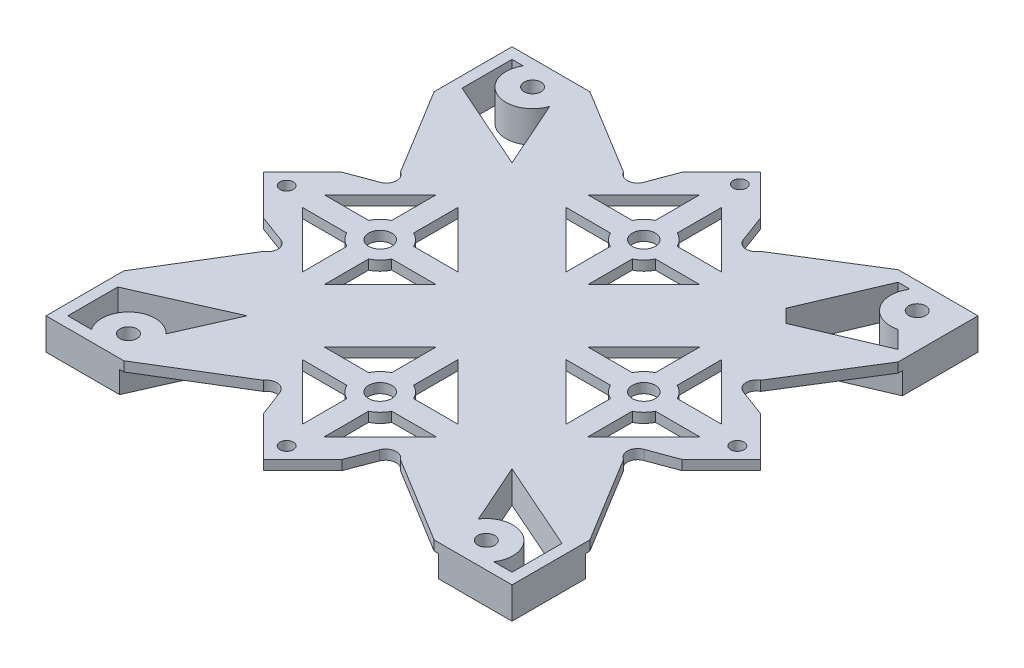
from build123d import *

# Parameters (mm, degrees)
SKETCH1_W            = 97.6
SKETCH1_H            = 97.6
BOSS_EXTRUDE1_DEPTH  = 2
SKETCH3_R            = 1.25
CUT_EXTRUDE1_DEPTH   = 10
FILLET1_R            = 0.2
SKETCH5_R            = 1.25
SKETCH5_R_2          = 1.248424064
SKETCH5_R_3          = 2.375
CUT_EXTRUDE2_DEPTH   = 10
SKETCH6_W            = 104.867444639
SKETCH6_H            = 104.070743389
SKETCH6_W_2          = 97.6
SKETCH6_H_2          = 97.6
BOSS_EXTRUDE2_DEPTH  = 2
SKETCH9_W            = 104.867444639
SKETCH9_H            = 104.070743389
CUT_EXTRUDE3_DEPTH   = 2
SKETCH11_R           = 1.25
BOSS_EXTRUDE3_DEPTH  = 4.5
CUT_EXTRUDE4_DEPTH   = 4.5
BOSS_EXTRUDE4_DEPTH  = 2
SKETCH15_R           = 1.25
SKETCH15_R_2         = 2.375
SKETCH15_R_3         = 1.248424064
CUT_EXTRUDE5_DEPTH   = 9.5
SKETCH16_R           = 1.25
BOSS_EXTRUDE10_DEPTH = 4.5
CUT_EXTRUDE6_DEPTH   = 1.85
SKETCH18_R           = 1.75
CUT_EXTRUDE7_DEPTH   = 14
BOSS_EXTRUDE11_DEPTH = 13
CUT_EXTRUDE10_DEPTH  = 11
CUT_EXTRUDE11_DEPTH  = 11
BOSS_EXTRUDE13_DEPTH = 2
SKETCH33_W           = 24.159337572
SKETCH33_H           = 13.360853571
SKETCH33_W_2         = 23.642161886
SKETCH33_H_2         = 13
CUT_EXTRUDE13_DEPTH  = 0.75
SKETCH34_W           = 20.408967788
SKETCH34_H           = 13
SKETCH34_W_2         = 21.119256586
CUT_EXTRUDE14_DEPTH  = 0.75
SKETCH35_W           = 21.001738999
SKETCH35_H           = 13
SKETCH35_W_2         = 20.166168151
CUT_EXTRUDE15_DEPTH  = 0.75
SKETCH36_W           = 19.371210598
SKETCH36_H           = 13
SKETCH36_W_2         = 18.340258541
CUT_EXTRUDE16_DEPTH  = 0.75
SKETCH38_R           = 1.25
SKETCH38_R_2         = 1.248424064
BOSS_EXTRUDE14_DEPTH = 2
SKETCH39_R           = 1.25
SKETCH39_R_2         = 1.248424064
BOSS_EXTRUDE15_DEPTH = 2
SKETCH40_R           = 1.375
CUT_EXTRUDE17_DEPTH  = 9.5
BOSS_EXTRUDE16_DEPTH = 13
SKETCH42_W           = 35.804322021
SKETCH42_H           = 4.5
CUT_EXTRUDE18_DEPTH  = 0.2
SKETCH43_W           = 35.804322021
SKETCH43_H           = 4.5
CUT_EXTRUDE19_DEPTH  = 0.2
SKETCH44_W           = 36.004322021
SKETCH44_H           = 4.5
SKETCH44_W_2         = 35.931129692
CUT_EXTRUDE20_DEPTH  = 0.2
SKETCH45_W           = 35.931129692
SKETCH45_H           = 4.5
SKETCH45_W_2         = 36.004322021
CUT_EXTRUDE21_DEPTH  = 0.2
SKETCH46_W           = 35.804322021
SKETCH46_H           = 4.5
CUT_EXTRUDE22_DEPTH  = 0.2
SKETCH47_W           = 35.804322021
SKETCH47_H           = 4.5
CUT_EXTRUDE23_DEPTH  = 0.2
SKETCH48_W           = 35.931129692
SKETCH48_H           = 4.5
SKETCH48_W_2         = 36.004322021
CUT_EXTRUDE24_DEPTH  = 0.2
SKETCH49_W           = 35.931129692
SKETCH49_H           = 4.5
SKETCH49_W_2         = 36.004322021
CUT_EXTRUDE25_DEPTH  = 0.2
SKETCH50_R           = 108.50704479
CUT_EXTRUDE26_DEPTH  = 6.5


with BuildPart() as part:
    # Sketch1 → Boss-Extrude1 (new body)
    with BuildSketch(Plane(origin=(0, 0, 0), x_dir=(1, 0, 0), z_dir=(0, 1, 0))):
        with Locations((48.8, 48.8)):
            Rectangle(SKETCH1_W, SKETCH1_H)
    extrude(amount=BOSS_EXTRUDE1_DEPTH)

    # Sketch3 → Cut-Extrude1 (cut)
    with BuildSketch(Plane.XZ):
        with BuildLine():
            Line((3, -84.3), (3, -94.6))
            Line((3, -94.6), (5.316079849, -94.6))
            ThreePointArc((5.316079849, -94.6), (7.792729855, -86.784550719), (15.285000001, -90.113353923))
            Line((15.285000001, -90.113353923), (21.472818771, -76.127181229))
            Line((21.472818771, -76.127181229), (3, -84.3))
        make_face()
        with BuildLine():
            Line((3, -13.3), (21.472818771, -21.472818771))
            Line((21.472818771, -21.472818771), (16.360495139, -9.917560959))
            ThreePointArc((16.360495139, -9.917560959), (8.975209709, -10.313312378), (7.873156109, -3))
            Line((7.873156109, -3), (3, -3))
            Line((3, -3), (3, -13.3))
        make_face()
        with BuildLine():
            Line((94.6, -13.3), (94.6, -3))
            Line((94.6, -3), (90.826843891, -3))
            ThreePointArc((90.826843891, -3), (89.267333256, -10.648445392), (81.630186258, -9.034513526))
            Line((81.630186258, -9.034513526), (76.127181229, -21.472818771))
            Line((76.127181229, -21.472818771), (94.6, -13.3))
        make_face()
        with BuildLine():
            Line((91.027327292, -86.172672708), (94.6, -82.6))
            Line((94.6, -82.6), (73.674141566, -73.674141566))
            Line((73.674141566, -73.674141566), (82.6, -94.6))
            Line((82.6, -94.6), (85.116873323, -94.6))
            ThreePointArc((85.116873323, -94.6), (85.157069093, -88.341897208), (91.027327292, -86.172672708))
        make_face()
        with Locations((89.66, -91.5)):
            Circle(SKETCH3_R)
        with Locations((10.05, -91.8)):
            Circle(SKETCH3_R)
        with Locations((12.45, -6.05)):
            Circle(SKETCH3_R)
        with Locations((86.25, -6.05)):
            Circle(SKETCH3_R)
    extrude(amount=-CUT_EXTRUDE1_DEPTH, mode=Mode.SUBTRACT)

    # Fillet1
    fillet1_edges = [part.edges().sort_by_distance(p)[0] for p in [
        (85.116873323, 1, -94.6),
    ]]
    fillet(fillet1_edges, radius=FILLET1_R)

    # Sketch5 → Cut-Extrude2 (cut)
    with BuildSketch(Plane.XZ):
        with BuildLine():
            Line((51.05, -80.617052601), (51.05, -89.767052601))
            Line((51.05, -89.767052601), (62.582493929, -78.234558673))
            Line((62.582493929, -78.234558673), (53.432493929, -78.234558673))
            ThreePointArc((53.432493929, -78.234558673), (52.441599923, -79.626158596), (51.05, -80.617052601))
        make_face()
        with BuildLine():
            Line((46.55, -89.767052601), (46.55, -80.617052601))
            ThreePointArc((46.55, -80.617052601), (45.158400077, -79.626158596), (44.167506071, -78.234558673))
            Line((44.167506071, -78.234558673), (35.017506071, -78.234558673))
            Line((35.017506071, -78.234558673), (46.55, -89.767052601))
        make_face()
        with BuildLine():
            Line((35.017506071, -73.734558673), (44.167506071, -73.734558673))
            ThreePointArc((44.167506071, -73.734558673), (45.158400077, -72.34295875), (46.55, -71.352064744))
            Line((46.55, -71.352064744), (46.55, -62.202064744))
            Line((46.55, -62.202064744), (35.017506071, -73.734558673))
        make_face()
        with BuildLine():
            ThreePointArc((51.05, -71.352064744), (52.441599923, -72.34295875), (53.432493929, -73.734558673))
            Line((53.432493929, -73.734558673), (62.582493929, -73.734558673))
            Line((62.582493929, -73.734558673), (51.05, -62.202064744))
            Line((51.05, -62.202064744), (51.05, -71.352064744))
        make_face()
        with BuildLine():
            Line((73.734558673, -35.017506071), (62.202064744, -46.55))
            Line((62.202064744, -46.55), (71.352064744, -46.55))
            ThreePointArc((71.352064744, -46.55), (72.34295875, -45.158400077), (73.734558673, -44.167506071))
            Line((73.734558673, -44.167506071), (73.734558673, -35.017506071))
        make_face()
        with BuildLine():
            ThreePointArc((73.734558673, -53.432493929), (72.34295875, -52.441599923), (71.352064744, -51.05))
            Line((71.352064744, -51.05), (62.202064744, -51.05))
            Line((62.202064744, -51.05), (73.734558673, -62.582493929))
            Line((73.734558673, -62.582493929), (73.734558673, -53.432493929))
        make_face()
        with BuildLine():
            Line((78.234558673, -35.017506071), (78.234558673, -44.167506071))
            ThreePointArc((78.234558673, -44.167506071), (79.626158596, -45.158400077), (80.617052601, -46.55))
            Line((80.617052601, -46.55), (89.767052601, -46.55))
            Line((89.767052601, -46.55), (78.234558673, -35.017506071))
        make_face()
        with BuildLine():
            ThreePointArc((80.617052601, -51.05), (79.626158596, -52.441599923), (78.234558673, -53.432493929))
            Line((78.234558673, -53.432493929), (78.234558673, -62.582493929))
            Line((78.234558673, -62.582493929), (89.767052601, -51.05))
            Line((89.767052601, -51.05), (80.617052601, -51.05))
        make_face()
        with BuildLine():
            Line((46.55, -16.982947399), (46.55, -7.832947399))
            Line((46.55, -7.832947399), (35.017506071, -19.365441327))
            Line((35.017506071, -19.365441327), (44.167506071, -19.365441327))
            ThreePointArc((44.167506071, -19.365441327), (45.158400077, -17.973841404), (46.55, -16.982947399))
        make_face()
        with BuildLine():
            Line((51.05, -7.832947399), (51.05, -16.982947399))
            ThreePointArc((51.05, -16.982947399), (52.441599923, -17.973841404), (53.432493929, -19.365441327))
            Line((53.432493929, -19.365441327), (62.582493929, -19.365441327))
            Line((62.582493929, -19.365441327), (51.05, -7.832947399))
        make_face()
        with BuildLine():
            ThreePointArc((46.55, -26.247935256), (45.158400077, -25.25704125), (44.167506071, -23.865441327))
            Line((44.167506071, -23.865441327), (35.017506071, -23.865441327))
            Line((35.017506071, -23.865441327), (46.55, -35.397935256))
            Line((46.55, -35.397935256), (46.55, -26.247935256))
        make_face()
        with BuildLine():
            Line((62.582493929, -23.865441327), (53.432493929, -23.865441327))
            ThreePointArc((53.432493929, -23.865441327), (52.441599923, -25.25704125), (51.05, -26.247935256))
            Line((51.05, -26.247935256), (51.05, -35.397935256))
            Line((51.05, -35.397935256), (62.582493929, -23.865441327))
        make_face()
        with BuildLine():
            Line((23.865441327, -62.582493929), (35.397935256, -51.05))
            Line((35.397935256, -51.05), (26.247935256, -51.05))
            ThreePointArc((26.247935256, -51.05), (25.25704125, -52.441599923), (23.865441327, -53.432493929))
            Line((23.865441327, -53.432493929), (23.865441327, -62.582493929))
        make_face()
        with BuildLine():
            Line((19.365441327, -62.582493929), (19.365441327, -53.432493929))
            ThreePointArc((19.365441327, -53.432493929), (17.973841404, -52.441599923), (16.982947399, -51.05))
            Line((16.982947399, -51.05), (7.832947399, -51.05))
            Line((7.832947399, -51.05), (19.365441327, -62.582493929))
        make_face()
        with BuildLine():
            ThreePointArc((23.865441327, -44.167506071), (25.25704125, -45.158400077), (26.247935256, -46.55))
            Line((26.247935256, -46.55), (35.397935256, -46.55))
            Line((35.397935256, -46.55), (23.865441327, -35.017506071))
            Line((23.865441327, -35.017506071), (23.865441327, -44.167506071))
        make_face()
        with BuildLine():
            Line((7.832947399, -46.55), (16.982947399, -46.55))
            ThreePointArc((16.982947399, -46.55), (17.973841404, -45.158400077), (19.365441327, -44.167506071))
            Line((19.365441327, -44.167506071), (19.365441327, -35.017506071))
            Line((19.365441327, -35.017506071), (7.832947399, -46.55))
        make_face()
        with Locations((48.8, -95.854595373)):
            Circle(SKETCH5_R)
        with Locations((95.84456992, -48.8)):
            Circle(SKETCH5_R_2)
        with Locations((1.75, -48.8)):
            Circle(SKETCH5_R)
        with Locations((48.8, -1.75)):
            Circle(SKETCH5_R)
        with Locations((48.8, -75.984558673)):
            Circle(SKETCH5_R_3)
        with Locations((75.984558673, -48.8)):
            Circle(SKETCH5_R_3)
        with Locations((48.8, -21.615441327)):
            Circle(SKETCH5_R_3)
        with Locations((21.615441327, -48.8)):
            Circle(SKETCH5_R_3)
    extrude(amount=-CUT_EXTRUDE2_DEPTH, mode=Mode.SUBTRACT)

    # Sketch6 → Boss-Extrude2 (add)
    with BuildSketch(Plane(origin=(0, 2, 0), x_dir=(1, 0, 0), z_dir=(0, 1, 0))):
        with Locations((49.842483603, 49.323375799)):
            Rectangle(SKETCH6_W, SKETCH6_H)
        with Locations((48.8, 48.8)):
            Rectangle(SKETCH6_W_2, SKETCH6_H_2, mode=Mode.SUBTRACT)
    extrude(amount=-BOSS_EXTRUDE2_DEPTH)

    # Sketch9 → Cut-Extrude3 (cut)
    with BuildSketch(Plane(origin=(0, 2, 0), x_dir=(1, 0, 0), z_dir=(0, 1, 0))):
        with Locations((49.842483603, 49.323375799)):
            Rectangle(SKETCH9_W, SKETCH9_H)
        Polygon((81.575043976, 97.6), (97.6, 97.6), (97.6, 81.575043976), (97.6, 51.29456992), (100.09456992, 48.8), (97.6, 46.30543008), (97.6, 15.581273054), (97.6, 0), (82.018726946, 0), (51.29456992, 0), (48.8, -2.49456992), (46.30543008, 0), (15.581273054, 0), (0, 0), (0, 15.581273054), (0, 46.30543008), (-2.49456992, 48.8), (0, 51.29456992), (0, 82.018726946), (0, 97.6), (15.581273054, 97.6), (46.30543008, 97.6), (48.8, 100.09456992), (51.29456992, 97.6), align=None, mode=Mode.SUBTRACT)
        with BuildLine():
            Line((40.668272016, 91.962841937), (46.30543008, 97.6))
            Line((46.30543008, 97.6), (15.581273054, 97.6))
            Line((15.581273054, 97.6), (34.657864376, 85.952434296))
            ThreePointArc((34.657864376, 85.952434296), (36.694771141, 84.840299118), (38.55, 86.234558673))
            Line((38.55, 86.234558673), (40.668272016, 91.962841937))
        make_face()
        with BuildLine():
            Line((62.942135624, 85.952434296), (81.575043976, 97.6))
            Line((81.575043976, 97.6), (51.29456992, 97.6))
            Line((51.29456992, 97.6), (56.931727984, 91.962841937))
            Line((56.931727984, 91.962841937), (59.05, 86.234558673))
            ThreePointArc((59.05, 86.234558673), (60.905228859, 84.840299118), (62.942135624, 85.952434296))
        make_face()
        with BuildLine():
            Line((97.6, 51.29456992), (97.6, 81.575043976))
            Line((97.6, 81.575043976), (85.952434296, 62.942135624))
            ThreePointArc((85.952434296, 62.942135624), (84.840299118, 60.905228859), (86.234558673, 59.05))
            Line((86.234558673, 59.05), (91.962841937, 56.931727984))
            Line((91.962841937, 56.931727984), (97.6, 51.29456992))
        make_face()
        with BuildLine():
            Line((97.6, 15.581273054), (97.6, 46.30543008))
            Line((97.6, 46.30543008), (91.962841937, 40.668272016))
            Line((91.962841937, 40.668272016), (86.234558673, 38.55))
            ThreePointArc((86.234558673, 38.55), (84.840299118, 36.694771141), (85.952434296, 34.657864376))
            Line((85.952434296, 34.657864376), (97.6, 15.581273054))
        make_face()
        with BuildLine():
            Line((51.29456992, 0), (82.018726946, 0))
            Line((82.018726946, 0), (62.942135624, 11.647565704))
            ThreePointArc((62.942135624, 11.647565704), (60.858639354, 12.601902927), (59.05, 11.194586358))
            Line((59.05, 11.194586358), (56.931727984, 5.637158063))
            Line((56.931727984, 5.637158063), (51.29456992, 0))
        make_face()
        with BuildLine():
            Line((15.581273054, 0), (46.30543008, 0))
            Line((46.30543008, 0), (40.668272016, 5.637158063))
            Line((40.668272016, 5.637158063), (38.55, 11.194586358))
            ThreePointArc((38.55, 11.194586358), (36.741360646, 12.601902927), (34.657864376, 11.647565704))
            Line((34.657864376, 11.647565704), (15.581273054, 0))
        make_face()
        with BuildLine():
            Line((5.637158063, 40.668272016), (0, 46.30543008))
            Line((0, 46.30543008), (0, 15.581273054))
            Line((0, 15.581273054), (11.647565704, 34.657864376))
            ThreePointArc((11.647565704, 34.657864376), (12.759700882, 36.694771141), (11.365441327, 38.55))
            Line((11.365441327, 38.55), (5.637158063, 40.668272016))
        make_face()
        with BuildLine():
            Line((11.647565704, 62.942135624), (0, 82.018726946))
            Line((0, 82.018726946), (0, 51.29456992))
            Line((0, 51.29456992), (5.637158063, 56.931727984))
            Line((5.637158063, 56.931727984), (11.365441327, 59.05))
            ThreePointArc((11.365441327, 59.05), (12.759700882, 60.905228859), (11.647565704, 62.942135624))
        make_face()
    extrude(amount=-CUT_EXTRUDE3_DEPTH, mode=Mode.SUBTRACT)

    # Sketch11 → Boss-Extrude3 (add)
    with BuildSketch(Plane.XZ):
        Polygon((97.6, -97.6), (81.575043976, -97.6), (69.655336569, -69.655336569), (97.6, -81.575043976), align=None)
        with Locations((89.66, -91.5)):
            Circle(SKETCH11_R, mode=Mode.SUBTRACT)
        with BuildLine():
            ThreePointArc((84.752862341, -94.6), (84.926573132, -94.499118926), (84.92504261, -94.298245614))
            ThreePointArc((84.92504261, -94.298245614), (85.26210654, -88.197193145), (91.027327292, -86.172672708))
            Line((91.027327292, -86.172672708), (94.6, -82.6))
            Line((94.6, -82.6), (73.674141566, -73.674141566))
            Line((73.674141566, -73.674141566), (82.6, -94.6))
            Line((82.6, -94.6), (84.752862341, -94.6))
        make_face(mode=Mode.SUBTRACT)
        Polygon((48.8, -49.789949494), (47.810050506, -48.8), (26.169211238, -70.440839268), (27.944663431, -69.655336569), (27.159160732, -71.430788762), align=None)
        Polygon((71.430788762, -27.159160732), (69.655336569, -27.944663431), (70.440839268, -26.169211238), (48.8, -47.810050506), (49.789949494, -48.8), align=None)
        Polygon((47.810050506, -48.8), (48.8, -47.810050506), (27.159160732, -26.169211238), (27.944663431, -27.944663431), (26.169211238, -27.159160732), align=None)
        Polygon((71.381631816, -70.391682322), (49.789949494, -48.8), (48.8, -49.789949494), (70.391682322, -71.381631816), (69.655336569, -69.655336569), align=None)
        Polygon((49.789949494, -48.8), (48.8, -47.810050506), (47.810050506, -48.8), (48.8, -49.789949494), align=None)
        Polygon((15.581273054, -97.6), (0, -97.6), (0, -82.018726946), (27.944663431, -69.655336569), align=None)
        with Locations((10.05, -91.8)):
            Circle(SKETCH11_R, mode=Mode.SUBTRACT)
        with BuildLine():
            Line((21.472818771, -76.127181229), (15.285000001, -90.113353923))
            ThreePointArc((15.285000001, -90.113353923), (7.792729855, -86.784550719), (5.316079849, -94.6))
            Line((5.316079849, -94.6), (3, -94.6))
            Line((3, -94.6), (3, -84.3))
            Line((3, -84.3), (21.472818771, -76.127181229))
        make_face(mode=Mode.SUBTRACT)
        Polygon((0, 0), (15.581273054, 0), (27.944663431, -27.944663431), (0, -15.581273054), align=None)
        with Locations((12.45, -6.05)):
            Circle(SKETCH11_R, mode=Mode.SUBTRACT)
        with BuildLine():
            Line((3, -3), (7.873156109, -3))
            ThreePointArc((7.873156109, -3), (8.975209709, -10.313312378), (16.360495139, -9.917560959))
            Line((16.360495139, -9.917560959), (21.472818771, -21.472818771))
            Line((21.472818771, -21.472818771), (3, -13.3))
            Line((3, -13.3), (3, -3))
        make_face(mode=Mode.SUBTRACT)
        Polygon((82.018726946, 0), (97.6, 0), (97.6, -15.581273054), (69.655336569, -27.944663431), align=None)
        with Locations((86.25, -6.05)):
            Circle(SKETCH11_R, mode=Mode.SUBTRACT)
        with BuildLine():
            Line((76.127181229, -21.472818771), (81.630186258, -9.034513526))
            ThreePointArc((81.630186258, -9.034513526), (89.267333256, -10.648445392), (90.826843891, -3))
            Line((90.826843891, -3), (94.6, -3))
            Line((94.6, -3), (94.6, -13.3))
            Line((94.6, -13.3), (76.127181229, -21.472818771))
        make_face(mode=Mode.SUBTRACT)
    extrude(amount=BOSS_EXTRUDE3_DEPTH)

    # Sketch12 → Cut-Extrude4 (cut)
    with BuildSketch(Plane.XZ.offset(4.5)):
        Polygon((26.876318019, -71.14794605), (71.148273589, -26.875990479), (70.724009521, -26.451726411), (26.45205395, -70.723681981), align=None)
        Polygon((26.45205395, -26.876318019), (70.724009521, -71.148273589), (71.148273589, -70.724009521), (26.876318019, -26.45205395), align=None)
    extrude(amount=-CUT_EXTRUDE4_DEPTH, mode=Mode.SUBTRACT)

    # Sketch13 → Boss-Extrude4 (add)
    with BuildSketch(Plane.XZ.offset(4.5)):
        with BuildLine():
            Line((0, -97.6), (0, -82.018726946))
            Line((0, -82.018726946), (11.647565704, -62.942135624))
            ThreePointArc((11.647565704, -62.942135624), (12.759700882, -60.905228859), (11.365441327, -59.05))
            Line((11.365441327, -59.05), (5.637158063, -56.931727984))
            Line((5.637158063, -56.931727984), (-2.49456992, -48.8))
            Line((-2.49456992, -48.8), (5.637158063, -40.668272016))
            Line((5.637158063, -40.668272016), (11.365441327, -38.55))
            ThreePointArc((11.365441327, -38.55), (12.759700882, -36.694771141), (11.647565704, -34.657864376))
            Line((11.647565704, -34.657864376), (0, -15.581273054))
            Line((0, -15.581273054), (0, 0))
            Line((0, 0), (15.581273054, 0))
            Line((15.581273054, 0), (34.657864376, -11.647565704))
            ThreePointArc((34.657864376, -11.647565704), (36.741360646, -12.601902927), (38.55, -11.194586358))
            Line((38.55, -11.194586358), (40.668272016, -5.637158063))
            Line((40.668272016, -5.637158063), (48.8, 2.49456992))
            Line((48.8, 2.49456992), (56.931727984, -5.637158063))
            Line((56.931727984, -5.637158063), (59.05, -11.194586358))
            ThreePointArc((59.05, -11.194586358), (60.858639354, -12.601902927), (62.942135624, -11.647565704))
            Line((62.942135624, -11.647565704), (82.018726946, 0))
            Line((82.018726946, 0), (97.6, 0))
            Line((97.6, 0), (97.6, -15.581273054))
            Line((97.6, -15.581273054), (85.952434296, -34.657864376))
            ThreePointArc((85.952434296, -34.657864376), (84.840299118, -36.694771141), (86.234558673, -38.55))
            Line((86.234558673, -38.55), (91.962841937, -40.668272016))
            Line((91.962841937, -40.668272016), (100.09456992, -48.8))
            Line((100.09456992, -48.8), (91.962841937, -56.931727984))
            Line((91.962841937, -56.931727984), (86.234558673, -59.05))
            ThreePointArc((86.234558673, -59.05), (84.840299118, -60.905228859), (85.952434296, -62.942135624))
            Line((85.952434296, -62.942135624), (97.6, -81.575043976))
            Line((97.6, -81.575043976), (97.6, -97.6))
            Line((97.6, -97.6), (81.575043976, -97.6))
            Line((81.575043976, -97.6), (62.942135624, -85.952434296))
            ThreePointArc((62.942135624, -85.952434296), (60.905228859, -84.840299118), (59.05, -86.234558673))
            Line((59.05, -86.234558673), (56.931727984, -91.962841937))
            Line((56.931727984, -91.962841937), (48.8, -100.09456992))
            Line((48.8, -100.09456992), (40.668272016, -91.962841937))
            Line((40.668272016, -91.962841937), (38.55, -86.234558673))
            ThreePointArc((38.55, -86.234558673), (36.694771141, -84.840299118), (34.657864376, -85.952434296))
            Line((34.657864376, -85.952434296), (15.581273054, -97.6))
            Line((15.581273054, -97.6), (0, -97.6))
        make_face()
    extrude(amount=BOSS_EXTRUDE4_DEPTH)

    # Sketch15 → Cut-Extrude5 (cut, through all)
    with BuildSketch(Plane.XZ.offset(6.5)):
        with BuildLine():
            ThreePointArc((53.432493929, -73.734558673), (52.441599923, -72.34295875), (51.05, -71.352064744))
            Line((51.05, -71.352064744), (51.05, -62.202064744))
            Line((51.05, -62.202064744), (62.582493929, -73.734558673))
            Line((62.582493929, -73.734558673), (53.432493929, -73.734558673))
        make_face()
        with BuildLine():
            ThreePointArc((51.05, -80.617052601), (52.441599923, -79.626158596), (53.432493929, -78.234558673))
            Line((53.432493929, -78.234558673), (62.582493929, -78.234558673))
            Line((62.582493929, -78.234558673), (51.05, -89.767052601))
            Line((51.05, -89.767052601), (51.05, -80.617052601))
        make_face()
        with BuildLine():
            ThreePointArc((44.167506071, -78.234558673), (45.158400077, -79.626158596), (46.55, -80.617052601))
            Line((46.55, -80.617052601), (46.55, -89.767052601))
            Line((46.55, -89.767052601), (35.017506071, -78.234558673))
            Line((35.017506071, -78.234558673), (44.167506071, -78.234558673))
        make_face()
        with BuildLine():
            ThreePointArc((46.55, -71.352064744), (45.158400077, -72.34295875), (44.167506071, -73.734558673))
            Line((44.167506071, -73.734558673), (35.017506071, -73.734558673))
            Line((35.017506071, -73.734558673), (46.55, -62.202064744))
            Line((46.55, -62.202064744), (46.55, -71.352064744))
        make_face()
        with BuildLine():
            ThreePointArc((15.285000001, -90.113353923), (7.792729855, -86.784550719), (5.316079849, -94.6))
            Line((5.316079849, -94.6), (3, -94.6))
            Line((3, -94.6), (3, -84.3))
            Line((3, -84.3), (21.472818771, -76.127181229))
            Line((21.472818771, -76.127181229), (15.285000001, -90.113353923))
        make_face()
        with Locations((10.05, -91.8)):
            Circle(SKETCH15_R)
        with BuildLine():
            ThreePointArc((16.982947399, -51.05), (17.973841404, -52.441599923), (19.365441327, -53.432493929))
            Line((19.365441327, -53.432493929), (19.365441327, -62.582493929))
            Line((19.365441327, -62.582493929), (7.832947399, -51.05))
            Line((7.832947399, -51.05), (16.982947399, -51.05))
        make_face()
        with BuildLine():
            ThreePointArc((19.365441327, -44.167506071), (17.973841404, -45.158400077), (16.982947399, -46.55))
            Line((16.982947399, -46.55), (7.832947399, -46.55))
            Line((7.832947399, -46.55), (19.365441327, -35.017506071))
            Line((19.365441327, -35.017506071), (19.365441327, -44.167506071))
        make_face()
        with BuildLine():
            ThreePointArc((26.247935256, -46.55), (25.25704125, -45.158400077), (23.865441327, -44.167506071))
            Line((23.865441327, -44.167506071), (23.865441327, -35.017506071))
            Line((23.865441327, -35.017506071), (35.397935256, -46.55))
            Line((35.397935256, -46.55), (26.247935256, -46.55))
        make_face()
        with BuildLine():
            ThreePointArc((23.865441327, -53.432493929), (25.25704125, -52.441599923), (26.247935256, -51.05))
            Line((26.247935256, -51.05), (35.397935256, -51.05))
            Line((35.397935256, -51.05), (23.865441327, -62.582493929))
            Line((23.865441327, -62.582493929), (23.865441327, -53.432493929))
        make_face()
        with Locations((21.615441327, -48.8)):
            Circle(SKETCH15_R_2)
        with Locations((1.75, -48.8)):
            Circle(SKETCH15_R)
        with BuildLine():
            ThreePointArc((7.873156109, -3), (8.975209709, -10.313312378), (16.360495139, -9.917560959))
            Line((16.360495139, -9.917560959), (21.472818771, -21.472818771))
            Line((21.472818771, -21.472818771), (3, -13.3))
            Line((3, -13.3), (3, -3))
            Line((3, -3), (7.873156109, -3))
        make_face()
        with Locations((12.45, -6.05)):
            Circle(SKETCH15_R)
        with BuildLine():
            ThreePointArc((71.352064744, -51.05), (72.34295875, -52.441599923), (73.734558673, -53.432493929))
            Line((73.734558673, -53.432493929), (73.734558673, -62.582493929))
            Line((73.734558673, -62.582493929), (62.202064744, -51.05))
            Line((62.202064744, -51.05), (71.352064744, -51.05))
        make_face()
        with BuildLine():
            ThreePointArc((78.234558673, -53.432493929), (79.626158596, -52.441599923), (80.617052601, -51.05))
            Line((80.617052601, -51.05), (89.767052601, -51.05))
            Line((89.767052601, -51.05), (78.234558673, -62.582493929))
            Line((78.234558673, -62.582493929), (78.234558673, -53.432493929))
        make_face()
        with BuildLine():
            ThreePointArc((73.734558673, -44.167506071), (72.34295875, -45.158400077), (71.352064744, -46.55))
            Line((71.352064744, -46.55), (62.202064744, -46.55))
            Line((62.202064744, -46.55), (73.734558673, -35.017506071))
            Line((73.734558673, -35.017506071), (73.734558673, -44.167506071))
        make_face()
        with BuildLine():
            ThreePointArc((80.617052601, -46.55), (79.626158596, -45.158400077), (78.234558673, -44.167506071))
            Line((78.234558673, -44.167506071), (78.234558673, -35.017506071))
            Line((78.234558673, -35.017506071), (89.767052601, -46.55))
            Line((89.767052601, -46.55), (80.617052601, -46.55))
        make_face()
        with Locations((89.66, -91.5)):
            Circle(SKETCH15_R)
        with BuildLine():
            ThreePointArc((81.630186258, -9.034513526), (89.267333256, -10.648445392), (90.826843891, -3))
            Line((90.826843891, -3), (94.6, -3))
            Line((94.6, -3), (94.6, -13.3))
            Line((94.6, -13.3), (76.127181229, -21.472818771))
            Line((76.127181229, -21.472818771), (81.630186258, -9.034513526))
        make_face()
        with BuildLine():
            ThreePointArc((51.05, -26.247935256), (52.441599923, -25.25704125), (53.432493929, -23.865441327))
            Line((53.432493929, -23.865441327), (62.582493929, -23.865441327))
            Line((62.582493929, -23.865441327), (51.05, -35.397935256))
            Line((51.05, -35.397935256), (51.05, -26.247935256))
        make_face()
        with BuildLine():
            ThreePointArc((53.432493929, -19.365441327), (52.441599923, -17.973841404), (51.05, -16.982947399))
            Line((51.05, -16.982947399), (51.05, -7.832947399))
            Line((51.05, -7.832947399), (62.582493929, -19.365441327))
            Line((62.582493929, -19.365441327), (53.432493929, -19.365441327))
        make_face()
        with BuildLine():
            ThreePointArc((44.167506071, -23.865441327), (45.158400077, -25.25704125), (46.55, -26.247935256))
            Line((46.55, -26.247935256), (46.55, -35.397935256))
            Line((46.55, -35.397935256), (35.017506071, -23.865441327))
            Line((35.017506071, -23.865441327), (44.167506071, -23.865441327))
        make_face()
        with BuildLine():
            ThreePointArc((46.55, -16.982947399), (45.158400077, -17.973841404), (44.167506071, -19.365441327))
            Line((44.167506071, -19.365441327), (35.017506071, -19.365441327))
            Line((35.017506071, -19.365441327), (46.55, -7.832947399))
            Line((46.55, -7.832947399), (46.55, -16.982947399))
        make_face()
        with Locations((48.8, -21.615441327)):
            Circle(SKETCH15_R_2)
        with Locations((48.8, -75.984558673)):
            Circle(SKETCH15_R_2)
        with Locations((48.8, -95.854595373)):
            Circle(SKETCH15_R)
        with Locations((95.84456992, -48.8)):
            Circle(SKETCH15_R_3)
        with Locations((48.8, -1.75)):
            Circle(SKETCH15_R)
        with Locations((75.984558673, -48.8)):
            Circle(SKETCH15_R_2)
        with Locations((86.25, -6.05)):
            Circle(SKETCH15_R)
        with BuildLine():
            Line((82.6, -94.6), (84.752862341, -94.6))
            ThreePointArc((84.752862341, -94.6), (84.926573132, -94.499118926), (84.92504261, -94.298245614))
            ThreePointArc((84.92504261, -94.298245614), (85.26210654, -88.197193145), (91.027327292, -86.172672708))
            Line((91.027327292, -86.172672708), (94.6, -82.6))
            Line((94.6, -82.6), (73.674141566, -73.674141566))
            Line((73.674141566, -73.674141566), (82.6, -94.6))
        make_face()
    extrude(amount=-CUT_EXTRUDE5_DEPTH, mode=Mode.SUBTRACT)

    # Sketch16 → Boss-Extrude10 (add)
    with BuildSketch(Plane.XZ.offset(6.5)):
        Polygon((0, 0), (0, -15.581273054), (26.169211238, -27.159160732), (47.810050506, -48.8), (26.169211238, -70.440839268), (0, -82.018726946), (0, -97.6), (15.581273054, -97.6), (27.159160732, -71.430788762), (48.8, -49.789949494), (70.391682322, -71.381631816), (81.575043976, -97.6), (97.6, -97.6), (97.6, -81.575043976), (71.381631816, -70.391682322), (49.789949494, -48.8), (71.430788762, -27.159160732), (97.6, -15.581273054), (97.6, 0), (82.018726946, 0), (70.440839268, -26.169211238), (48.8, -47.810050506), (27.159160732, -26.169211238), (15.581273054, 0), align=None)
        with BuildLine():
            Line((21.472818771, -21.472818771), (3, -13.3))
            Line((3, -13.3), (3, -3))
            Line((3, -3), (7.873156109, -3))
            ThreePointArc((7.873156109, -3), (8.975209709, -10.313312378), (16.360495139, -9.917560959))
            Line((16.360495139, -9.917560959), (21.472818771, -21.472818771))
        make_face(mode=Mode.SUBTRACT)
        with Locations((12.45, -6.05)):
            Circle(SKETCH16_R, mode=Mode.SUBTRACT)
        with BuildLine():
            Line((21.472818771, -76.127181229), (15.285000001, -90.113353923))
            ThreePointArc((15.285000001, -90.113353923), (7.792729855, -86.784550719), (5.316079849, -94.6))
            Line((5.316079849, -94.6), (3, -94.6))
            Line((3, -94.6), (3, -84.3))
            Line((3, -84.3), (21.472818771, -76.127181229))
        make_face(mode=Mode.SUBTRACT)
        with Locations((10.05, -91.8)):
            Circle(SKETCH16_R, mode=Mode.SUBTRACT)
        with BuildLine():
            Line((94.6, -82.6), (91.027327292, -86.172672708))
            ThreePointArc((91.027327292, -86.172672708), (85.26210654, -88.197193145), (84.92504261, -94.298245614))
            ThreePointArc((84.92504261, -94.298245614), (84.926573132, -94.499118926), (84.752862341, -94.6))
            Line((84.752862341, -94.6), (82.6, -94.6))
            Line((82.6, -94.6), (73.674141566, -73.674141566))
            Line((73.674141566, -73.674141566), (94.6, -82.6))
        make_face(mode=Mode.SUBTRACT)
        with Locations((89.66, -91.5)):
            Circle(SKETCH16_R, mode=Mode.SUBTRACT)
        with Locations((86.25, -6.05)):
            Circle(SKETCH16_R, mode=Mode.SUBTRACT)
        with BuildLine():
            Line((76.127181229, -21.472818771), (81.630186258, -9.034513526))
            ThreePointArc((81.630186258, -9.034513526), (89.267333256, -10.648445392), (90.826843891, -3))
            Line((90.826843891, -3), (94.6, -3))
            Line((94.6, -3), (94.6, -13.3))
            Line((94.6, -13.3), (76.127181229, -21.472818771))
        make_face(mode=Mode.SUBTRACT)
    extrude(amount=BOSS_EXTRUDE10_DEPTH)

    # Sketch17 → Cut-Extrude6 (cut)
    with BuildSketch(Plane.XZ.offset(11)):
        Polygon((26.45205395, -70.723681981), (26.876318019, -71.14794605), (48.8, -49.224264069), (48.375735931, -48.8), align=None)
        Polygon((26.45205395, -26.876318019), (48.375735931, -48.8), (48.8, -48.375735931), (26.876318019, -26.45205395), align=None)
        Polygon((48.8, -48.375735931), (49.224264069, -48.8), (71.148273589, -26.875990479), (70.724009521, -26.451726411), align=None)
        Polygon((48.375735931, -48.8), (48.8, -49.224264069), (49.224264069, -48.8), (48.8, -48.375735931), align=None)
        Polygon((49.224264069, -48.8), (48.8, -49.224264069), (70.724009521, -71.148273589), (71.148273589, -70.724009521), align=None)
    extrude(amount=-CUT_EXTRUDE6_DEPTH, mode=Mode.SUBTRACT)

    # Sketch18 → Cut-Extrude7 (cut, through all)
    with BuildSketch(Plane.XZ.offset(11)):
        with Locations((12.45, -6.05)):
            Circle(SKETCH18_R)
        with Locations((86.25, -6.05)):
            Circle(SKETCH18_R)
        with Locations((10.05, -91.8)):
            Circle(SKETCH18_R)
        with Locations((89.66, -91.5)):
            Circle(SKETCH18_R)
    extrude(amount=-CUT_EXTRUDE7_DEPTH, mode=Mode.SUBTRACT)

    # Sketch20 → Boss-Extrude11 (add)
    with BuildSketch(Plane.XZ.offset(11)):
        Polygon((78.43455017, -75.704678732), (75.704678732, -78.43455017), (73.674141566, -73.674141566), align=None)
    extrude(amount=-BOSS_EXTRUDE11_DEPTH)

    # Sketch19 → Cut-Extrude10 (cut)
    with BuildSketch(Plane.XZ.offset(11)):
        Polygon((76.528651212, -24.903743925), (72.116660746, -26.85571449), (75.298641261, -23.673733975), align=None)
        Polygon((75.10742839, -23.482521103), (71.430788762, -27.159160732), (72.116660746, -26.85571449), (75.298641261, -23.673733975), align=None)
        Polygon((70.74428551, -25.483339254), (73.926266025, -22.301358739), (72.696256075, -21.071348788), align=None)
        Polygon((70.440839268, -26.169211238), (74.117478897, -22.49257161), (73.926266025, -22.301358739), (70.74428551, -25.483339254), align=None)
        Polygon((24.903743925, -21.071348788), (26.85571449, -25.483339254), (23.673733975, -22.301358739), align=None)
        Polygon((23.482521103, -22.49257161), (27.159160732, -26.169211238), (26.85571449, -25.483339254), (23.673733975, -22.301358739), align=None)
        Polygon((26.169211238, -27.159160732), (22.49257161, -23.482521103), (22.301358739, -23.673733975), (25.483339254, -26.85571449), align=None)
        Polygon((21.071348788, -24.903743925), (25.483339254, -26.85571449), (22.301358739, -23.673733975), align=None)
        Polygon((21.071348788, -72.696256075), (25.483339254, -70.74428551), (22.301358739, -73.926266025), align=None)
        Polygon((22.301358739, -73.926266025), (22.49257161, -74.117478897), (26.169211238, -70.440839268), (25.483339254, -70.74428551), align=None)
        Polygon((26.85571449, -72.116660746), (27.159160732, -71.430788762), (23.482521103, -75.10742839), (23.673733975, -75.298641261), align=None)
        Polygon((23.673733975, -75.298641261), (24.903743925, -76.528651212), (26.85571449, -72.116660746), align=None)
        Polygon((72.58880733, -76.532590373), (70.685941391, -72.071495281), (73.867921907, -75.253475796), align=None)
        Polygon((75.253475796, -73.867921907), (76.532590373, -72.58880733), (72.071495281, -70.685941391), align=None)
        Polygon((72.071495281, -70.685941391), (71.381631816, -70.391682322), (75.055673598, -74.065724105), (75.253475796, -73.867921907), align=None)
        Polygon((73.867921907, -75.253475796), (74.065724105, -75.055673598), (70.391682322, -71.381631816), (70.685941391, -72.071495281), align=None)
    extrude(amount=-CUT_EXTRUDE10_DEPTH, mode=Mode.SUBTRACT)

    # Sketch21 → Cut-Extrude11 (cut)
    with BuildSketch(Plane.XZ.offset(11)):
        Polygon((76.528651212, -24.903743925), (75.10742839, -23.482521103), (79.741005768, -23.482521103), align=None)
        Polygon((72.696256075, -21.071348788), (74.117478897, -22.49257161), (74.117478897, -17.858994232), align=None)
        Polygon((17.858994232, -74.117478897), (21.071348788, -72.696256075), (22.49257161, -74.117478897), align=None)
        Polygon((23.482521103, -79.741005768), (24.903743925, -76.528651212), (23.482521103, -75.10742839), align=None)
        Polygon((72.58880733, -76.532590373), (74.065724105, -75.055673598), (74.065724105, -79.995086621), align=None)
        Polygon((79.995086621, -74.065724105), (76.532590373, -72.58880733), (75.055673598, -74.065724105), align=None)
        Polygon((23.482521103, -22.49257161), (23.482521103, -17.858994232), (24.903743925, -21.071348788), align=None)
        Polygon((17.858994232, -23.482521103), (21.071348788, -24.903743925), (22.49257161, -23.482521103), align=None)
    extrude(amount=-CUT_EXTRUDE11_DEPTH, mode=Mode.SUBTRACT)

    # Sketch31 → Boss-Extrude13 (add)
    with BuildSketch(Plane.XZ.offset(6.5)):
        Polygon((26.169211238, -27.159160732), (17.858994232, -23.482521103), (22.49257161, -23.482521103), align=None)
        Polygon((27.159160732, -26.169211238), (23.482521103, -17.858994232), (23.482521103, -22.49257161), align=None)
        Polygon((70.440839268, -26.169211238), (74.117478897, -22.49257161), (74.117478897, -17.858994232), align=None)
        Polygon((71.430788762, -27.159160732), (79.741005768, -23.482521103), (75.10742839, -23.482521103), align=None)
        Polygon((74.065724105, -79.995086621), (74.065724105, -75.055673598), (70.391682322, -71.381631816), align=None)
        Polygon((79.995086621, -74.065724105), (71.381631816, -70.391682322), (75.055673598, -74.065724105), align=None)
        Polygon((23.482521103, -79.741005768), (23.482521103, -75.10742839), (27.159160732, -71.430788762), align=None)
        Polygon((17.858994232, -74.117478897), (26.169211238, -70.440839268), (22.49257161, -74.117478897), align=None)
    extrude(amount=-BOSS_EXTRUDE13_DEPTH)

    # Sketch33 → Cut-Extrude13 (cut)
    with BuildSketch(Plane(origin=(97.6, 0, 0), x_dir=(0, 0, -1), z_dir=(1, 0, 0))):
        with Locations((85.520331214, -4.319573215)):
            Rectangle(SKETCH33_W, SKETCH33_H)
        with Locations((11.821080943, -4.5)):
            Rectangle(SKETCH33_W_2, SKETCH33_H_2)
    extrude(amount=-CUT_EXTRUDE13_DEPTH, mode=Mode.SUBTRACT)

    # Sketch34 → Cut-Extrude14 (cut)
    with BuildSketch(Plane(origin=(0, 0, -97.6), x_dir=(-1, 0, 0), z_dir=(0, 0, -1))):
        with Locations((-10.204483894, -4.5)):
            Rectangle(SKETCH34_W, SKETCH34_H)
        with Locations((-86.290371707, -4.5)):
            Rectangle(SKETCH34_W_2, SKETCH34_H)
    extrude(amount=-CUT_EXTRUDE14_DEPTH, mode=Mode.SUBTRACT)

    # Sketch35 → Cut-Extrude15 (cut)
    with BuildSketch(Plane.ZY):
        with Locations((-86.349130501, -4.5)):
            Rectangle(SKETCH35_W, SKETCH35_H)
        with Locations((-10.083084076, -4.5)):
            Rectangle(SKETCH35_W_2, SKETCH35_H)
    extrude(amount=-CUT_EXTRUDE15_DEPTH, mode=Mode.SUBTRACT)

    # Sketch36 → Cut-Extrude16 (cut)
    with BuildSketch(Plane.XY):
        with Locations((87.164394701, -4.5)):
            Rectangle(SKETCH36_W, SKETCH36_H)
        with Locations((9.920129271, -4.5)):
            Rectangle(SKETCH36_W_2, SKETCH36_H)
    extrude(amount=-CUT_EXTRUDE16_DEPTH, mode=Mode.SUBTRACT)

    # Sketch38 → Boss-Extrude14 (add)
    with BuildSketch(Plane.XZ.offset(6.5)):
        with Locations((48.8, -95.854595373)):
            Circle(SKETCH38_R)
        with Locations((95.84456992, -48.8)):
            Circle(SKETCH38_R_2)
        with Locations((48.8, -1.75)):
            Circle(SKETCH38_R)
        with Locations((1.75, -48.8)):
            Circle(SKETCH38_R)
    extrude(amount=-BOSS_EXTRUDE14_DEPTH)

    # Sketch39 → Boss-Extrude15 (add)
    with BuildSketch(Plane.XZ):
        with Locations((48.8, -1.75)):
            Circle(SKETCH39_R)
        with Locations((95.84456992, -48.8)):
            Circle(SKETCH39_R_2)
        with Locations((1.75, -48.8)):
            Circle(SKETCH39_R)
        with Locations((48.8, -95.854595373)):
            Circle(SKETCH39_R)
    extrude(amount=-BOSS_EXTRUDE15_DEPTH)

    # Sketch40 → Cut-Extrude17 (cut, through all)
    with BuildSketch(Plane.XZ.offset(6.5)):
        with Locations((2.32375, -48.8)):
            Circle(SKETCH40_R)
        with Locations((95.27625, -48.8)):
            Circle(SKETCH40_R)
        with Locations((48.8, -2.32375)):
            Circle(SKETCH40_R)
        with Locations((48.8, -95.78)):
            Circle(SKETCH40_R)
    extrude(amount=-CUT_EXTRUDE17_DEPTH, mode=Mode.SUBTRACT)

    # Sketch41 → Boss-Extrude16 (add)
    with BuildSketch(Plane.XZ.offset(11)):
        Polygon((70.738340107, -26.437395824), (48.8, -48.375735931), (49.224264069, -48.8), (71.162604176, -26.861659893), align=None)
        Polygon((49.224264069, -48.8), (48.8, -48.375735931), (48.375735931, -48.8), (48.8, -49.224264069), align=None)
        Polygon((48.8, -48.375735931), (26.876318019, -26.45205395), (26.45205395, -26.876318019), (48.375735931, -48.8), align=None)
        Polygon((48.8, -49.224264069), (48.375735931, -48.8), (26.45205395, -70.723681981), (26.876318019, -71.14794605), align=None)
        Polygon((71.145840263, -70.721576194), (49.224264069, -48.8), (48.8, -49.224264069), (70.721576194, -71.145840263), align=None)
    extrude(amount=-BOSS_EXTRUDE16_DEPTH)

    # Sketch42 → Cut-Extrude18 (cut)
    with BuildSketch(Plane(origin=(49.294974747, 0, -49.294974747), x_dir=(-0.707106781, 0, -0.707106781), z_dir=(0.707106781, 0, -0.707106781))):
        with Locations((18.602161011, -8.75)):
            Rectangle(SKETCH42_W, SKETCH42_H)
        with Locations((-18.602161011, -8.75)):
            Rectangle(SKETCH42_W, SKETCH42_H)
    extrude(amount=-CUT_EXTRUDE18_DEPTH, mode=Mode.SUBTRACT)

    # Sketch43 → Cut-Extrude19 (cut)
    with BuildSketch(Plane(origin=(48.305025253, 0, -48.305025253), x_dir=(0.707106781, 0, 0.707106781), z_dir=(-0.707106781, 0, 0.707106781))):
        with Locations((18.602161011, -8.75)):
            Rectangle(SKETCH43_W, SKETCH43_H)
        with Locations((-18.602161011, -8.75)):
            Rectangle(SKETCH43_W, SKETCH43_H)
    extrude(amount=-CUT_EXTRUDE19_DEPTH, mode=Mode.SUBTRACT)

    # Sketch44 → Cut-Extrude20 (cut)
    with BuildSketch(Plane(origin=(-0.494974747, 0, -0.494974747), x_dir=(-0.707106781, 0, 0.707106781), z_dir=(-0.707106781, 0, -0.707106781))):
        with Locations((-50.511460833, -8.75)):
            Rectangle(SKETCH44_W, SKETCH44_H)
        with Locations((-87.47918669, -8.75)):
            Rectangle(SKETCH44_W_2, SKETCH44_H)
    extrude(amount=-CUT_EXTRUDE20_DEPTH, mode=Mode.SUBTRACT)

    # Sketch45 → Cut-Extrude21 (cut)
    with BuildSketch(Plane(origin=(0.494974747, 0, 0.494974747), x_dir=(0.707106781, 0, -0.707106781), z_dir=(0.707106781, 0, 0.707106781))):
        with Locations((87.47918669, -8.75)):
            Rectangle(SKETCH45_W, SKETCH45_H)
        with Locations((50.511460833, -8.75)):
            Rectangle(SKETCH45_W_2, SKETCH45_H)
    extrude(amount=-CUT_EXTRUDE21_DEPTH, mode=Mode.SUBTRACT)

    # Sketch46 → Cut-Extrude22 (cut)
    with BuildSketch(Plane(origin=(48.305025253, 0, -48.305025253), x_dir=(0.707106781, 0, 0.707106781), z_dir=(-0.707106781, 0, 0.707106781))):
        with Locations((18.602161011, -2.25)):
            Rectangle(SKETCH46_W, SKETCH46_H)
        with Locations((-18.602161011, -2.25)):
            Rectangle(SKETCH46_W, SKETCH46_H)
    extrude(amount=-CUT_EXTRUDE22_DEPTH, mode=Mode.SUBTRACT)

    # Sketch47 → Cut-Extrude23 (cut)
    with BuildSketch(Plane(origin=(49.294974747, 0, -49.294974747), x_dir=(-0.707106781, 0, -0.707106781), z_dir=(0.707106781, 0, -0.707106781))):
        with Locations((18.602161011, -2.25)):
            Rectangle(SKETCH47_W, SKETCH47_H)
        with Locations((-18.602161011, -2.25)):
            Rectangle(SKETCH47_W, SKETCH47_H)
    extrude(amount=-CUT_EXTRUDE23_DEPTH, mode=Mode.SUBTRACT)

    # Sketch48 → Cut-Extrude24 (cut)
    with BuildSketch(Plane(origin=(-0.494974747, 0, -0.494974747), x_dir=(-0.707106781, 0, 0.707106781), z_dir=(-0.707106781, 0, -0.707106781))):
        with Locations((-87.47918669, -2.25)):
            Rectangle(SKETCH48_W, SKETCH48_H)
        with Locations((-50.511460833, -2.25)):
            Rectangle(SKETCH48_W_2, SKETCH48_H)
    extrude(amount=-CUT_EXTRUDE24_DEPTH, mode=Mode.SUBTRACT)

    # Sketch49 → Cut-Extrude25 (cut)
    with BuildSketch(Plane(origin=(0.494974747, 0, 0.494974747), x_dir=(0.707106781, 0, -0.707106781), z_dir=(0.707106781, 0, 0.707106781))):
        with Locations((87.47918669, -2.25)):
            Rectangle(SKETCH49_W, SKETCH49_H)
        with Locations((50.511460833, -2.25)):
            Rectangle(SKETCH49_W_2, SKETCH49_H)
    extrude(amount=-CUT_EXTRUDE25_DEPTH, mode=Mode.SUBTRACT)

    # Sketch50 → Cut-Extrude26 (cut)
    with BuildSketch(Plane(origin=(0, 2, 0), x_dir=(1, 0, 0), z_dir=(0, 1, 0))):
        with Locations((46.463889125, 47.156312842)):
            Circle(SKETCH50_R)
    extrude(amount=-CUT_EXTRUDE26_DEPTH, mode=Mode.SUBTRACT)


solid = part.part
